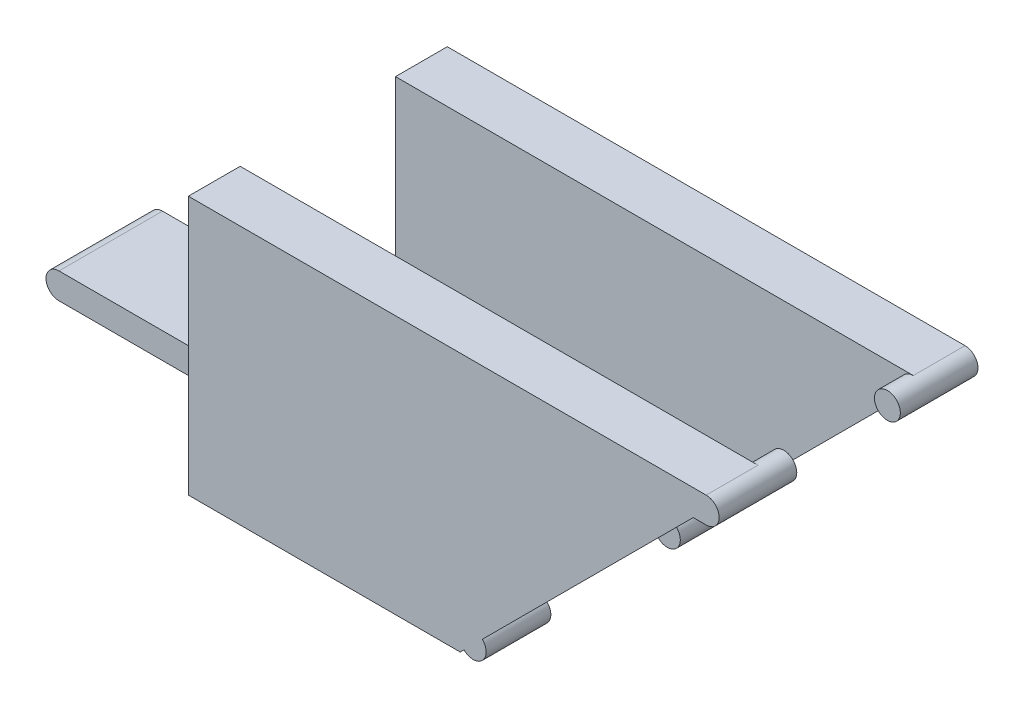
from build123d import *

# Parameters (mm, degrees)
SKETCH_1_W           = 40
SKETCH_1_H           = 20
EXTRUDE_1_DEPTH      = 20
SKETCH_2_W           = 8
SKETCH_2_H           = 4
EXTRUDE_2_DEPTH      = 16
SKETCH_4_W           = 12
SKETCH_4_H           = 18.32487869
CUT_EXTRUDE_2_DEPTH  = 41
SKETCH_7_W           = 12
SKETCH_7_H           = 4
CUT_EXTRUDE_4_DEPTH  = 20
SKETCH_5_R           = 1
EXTRUDE_3_DEPTH      = 10
SKETCH_6_W           = 8
SKETCH_6_H           = 25.038569191
CUT_EXTRUDE_3_DEPTH  = 10
CUT_EXTRUDE_8_DEPTH  = 20
SKETCH_13_R          = 1
EXTRUDE_5_DEPTH      = 8
CUT_EXTRUDE_10_DEPTH = 20
SKETCH_16_R          = 1
EXTRUDE_12_DEPTH     = 5
SKETCH_17_R          = 1
EXTRUDE_13_DEPTH     = 5


with BuildPart() as part:
    # 草图1 → 凸台-拉伸1 (new body)
    with BuildSketch(Plane(origin=(0, 0, 0), x_dir=(1, 0, 0), z_dir=(0, 1, 0))):
        with Locations((18, 0)):
            Rectangle(SKETCH_1_W, SKETCH_1_H)
    extrude(amount=EXTRUDE_1_DEPTH)

    # 草图2 → 凸台-拉伸2 (add)
    with BuildSketch(Plane.ZY.offset(2)):
        with Locations((0, 2)):
            Rectangle(SKETCH_2_W, SKETCH_2_H)
    extrude(amount=EXTRUDE_2_DEPTH)

    # 草图4 → 切除-拉伸2 (cut, through all)
    with BuildSketch(Plane.ZY.offset(2)):
        with Locations((0, 13.162439345)):
            Rectangle(SKETCH_4_W, SKETCH_4_H)
    extrude(amount=-CUT_EXTRUDE_2_DEPTH, mode=Mode.SUBTRACT)

    # 草图7 → 切除-拉伸4 (cut)
    with BuildSketch(Plane(origin=(38, 0, 0), x_dir=(0, 0, -1), z_dir=(1, 0, 0))):
        with Locations((0, 2)):
            Rectangle(SKETCH_7_W, SKETCH_7_H)
    extrude(amount=-CUT_EXTRUDE_4_DEPTH, mode=Mode.SUBTRACT)

    # 草图5 → 凸台-拉伸3 (add, symmetric)
    with BuildSketch(Plane.XY):
        with Locations((38, 19)):
            Circle(SKETCH_5_R)
        with Locations((38, 1)):
            Circle(SKETCH_5_R)
    extrude(amount=EXTRUDE_3_DEPTH, both=True)

    # 草图6 → 切除-拉伸3 (cut, symmetric)
    with BuildSketch(Plane(origin=(38, 0, 0), x_dir=(0, 0, -1), z_dir=(1, 0, 0))):
        with Locations((0, 10.475013396)):
            Rectangle(SKETCH_6_W, SKETCH_6_H)
    extrude(amount=CUT_EXTRUDE_3_DEPTH, both=True, mode=Mode.SUBTRACT)

    # 草图12 → 切除-拉伸8 (cut)
    with BuildSketch(Plane.XY.offset(4)):
        with BuildLine():
            Line((-5, 2), (-18.474771325, 2))
            Line((-18.474771325, 2), (-18.474771325, 0))
            Line((-18.474771325, 0), (-5, 0))
            ThreePointArc((-5, 0), (-6, 1), (-5, 2))
        make_face()
    extrude(amount=-CUT_EXTRUDE_8_DEPTH, mode=Mode.SUBTRACT)

    # 草图13 → 凸台-拉伸5 (add)
    with BuildSketch(Plane.XY.offset(4)):
        with Locations((-18, 3)):
            Circle(SKETCH_13_R)
    extrude(amount=-EXTRUDE_5_DEPTH)

    # 草图15 → 切除-拉伸10 (cut)
    with BuildSketch(Plane.XY.offset(10)):
        Polygon((19, 0), (39.887994795, 0), (38, 18), (37, 18), align=None)
    extrude(amount=-CUT_EXTRUDE_10_DEPTH, mode=Mode.SUBTRACT)

    # 草图16 → 凸台-拉伸12 (add)
    with BuildSketch(Plane.XY.offset(10)):
        with Locations((20, 1)):
            Circle(SKETCH_16_R)
    extrude(amount=-EXTRUDE_12_DEPTH)

    # 草图17 → 凸台-拉伸13 (add)
    with BuildSketch(Plane(origin=(0, 0, -10), x_dir=(-1, 0, 0), z_dir=(0, 0, -1))):
        with Locations((-20, 1)):
            Circle(SKETCH_17_R)
    extrude(amount=-EXTRUDE_13_DEPTH)


solid = part.part
